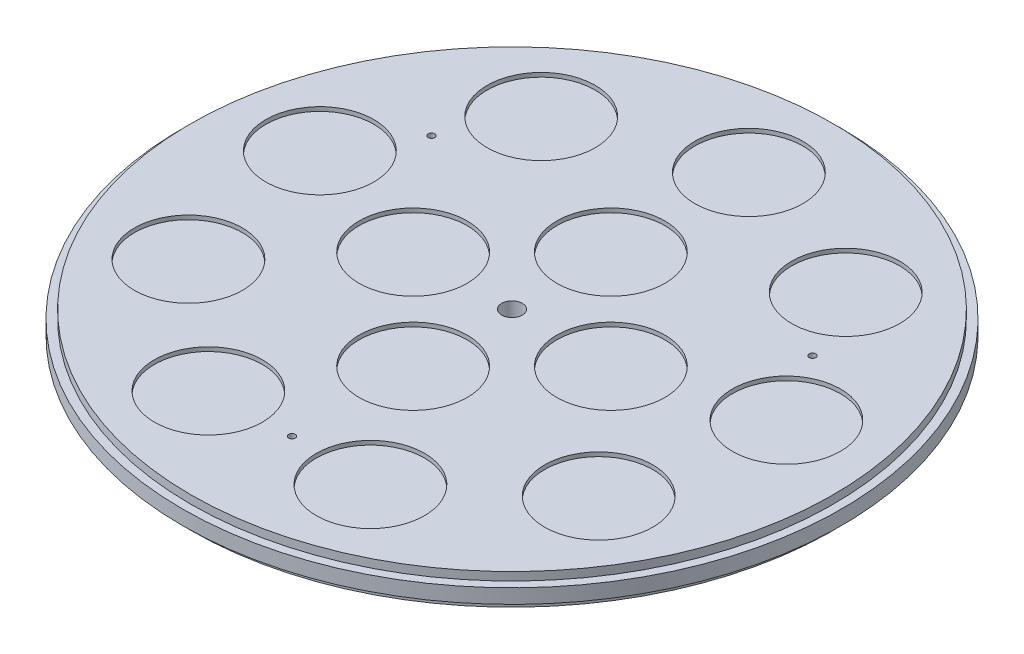
from build123d import *

# Parameters (mm, degrees)
ESQUISSE1_R                  = 160
BOSS_EXTRU_1_DEPTH           = 7.5
ESQUISSE2_R                  = 110.25
ENL_V_MAT_EXTRU_1_DEPTH      = 2
ESQUISSE3_R                  = 1.6
ENL_V_MAT_EXTRU_2_DEPTH      = 14
R_P_TITION_CIRCULAIRE1_COUNT = 3
ESQUISSE4_R                  = 1
ENL_V_MAT_EXTRU_3_DEPTH      = 14
ESQUISSE10_R                 = 5
ENL_V_MAT_EXTRU_6_DEPTH      = 11
ESQUISSE11_R                 = 160
ESQUISSE11_R_2               = 156
ENL_V_MAT_EXTRU_7_DEPTH      = 4
ESQUISSE8_R                  = 26.25
ENL_V_MAT_EXTRU_4_DEPTH      = 2
R_P_TITION_CIRCULAIRE2_COUNT = 9
ESQUISSE9_R                  = 26.25
ENL_V_MAT_EXTRU_5_DEPTH      = 2
R_P_TITION_CIRCULAIRE3_COUNT = 4


with BuildPart() as part:
    # Esquisse1 → Boss.-Extru.1 (new body, symmetric)
    with BuildSketch(Plane(origin=(0, 0, 0), x_dir=(1, 0, 0), z_dir=(0, 1, 0))):
        Circle(ESQUISSE1_R)
    extrude(amount=BOSS_EXTRU_1_DEPTH, both=True)

    # Esquisse2 → Enlèv. mat.-Extru.1 (cut)
    with BuildSketch(Plane.XZ.offset(7.5)):
        Circle(ESQUISSE2_R)
    extrude(amount=-ENL_V_MAT_EXTRU_1_DEPTH, mode=Mode.SUBTRACT)

    # Esquisse3 → Enlèv. mat.-Extru.2 (cut, through all)
    with BuildSketch(Plane(origin=(0, -5.5, 0), x_dir=(-1, 0, 0), z_dir=(0, -1, 0))):
        with Locations((0, -106.8)):
            Circle(ESQUISSE3_R)
    enl_v_mat_extru_2 = extrude(amount=-ENL_V_MAT_EXTRU_2_DEPTH, mode=Mode.SUBTRACT)

    # Répétition circulaire1: Enlèv. mat.-Extru.2 ×3 about axis
    r_p_tition_circulaire1_axis = Axis((0, 0, 0), (0, 1, 0))
    for i in range(1, R_P_TITION_CIRCULAIRE1_COUNT):
        add(enl_v_mat_extru_2.rotate(r_p_tition_circulaire1_axis, i * 360 / R_P_TITION_CIRCULAIRE1_COUNT), mode=Mode.SUBTRACT)

    # Esquisse4 → Enlèv. mat.-Extru.3 (cut, through all)
    with BuildSketch(Plane.XZ.offset(5.5)):
        Circle(ESQUISSE4_R)
    extrude(amount=-ENL_V_MAT_EXTRU_3_DEPTH, mode=Mode.SUBTRACT)

    # Esquisse10 → Enlèv. mat.-Extru.6 (cut)
    with BuildSketch(Plane(origin=(0, 7.5, 0), x_dir=(1, 0, 0), z_dir=(0, 1, 0))):
        Circle(ESQUISSE10_R)
    extrude(amount=-ENL_V_MAT_EXTRU_6_DEPTH, mode=Mode.SUBTRACT)

    # Esquisse11 → Enlèv. mat.-Extru.7 (cut)
    with BuildSketch(Plane(origin=(0, -7.5, 0), x_dir=(1, 0, 0), z_dir=(0, 1, 0))):
        Circle(ESQUISSE11_R)
        Circle(ESQUISSE11_R_2, mode=Mode.SUBTRACT)
    enl_v_mat_extru_7 = extrude(amount=ENL_V_MAT_EXTRU_7_DEPTH, mode=Mode.SUBTRACT)

    # Symétrie1: Enlèv. mat.-Extru.7 across plane
    add(enl_v_mat_extru_7.mirror(Plane.ZX), mode=Mode.SUBTRACT)

    # Esquisse8 → Enlèv. mat.-Extru.4 (cut)
    with BuildSketch(Plane(origin=(0, 7.5, 0), x_dir=(1, 0, 0), z_dir=(0, 1, 0))):
        with Locations((0, 115)):
            Circle(ESQUISSE8_R)
    enl_v_mat_extru_4 = extrude(amount=-ENL_V_MAT_EXTRU_4_DEPTH, mode=Mode.SUBTRACT)

    # Répétition circulaire2: Enlèv. mat.-Extru.4 ×9 about axis
    r_p_tition_circulaire2_axis = Axis((0, 0, 0), (0, 1, 0))
    for i in range(1, R_P_TITION_CIRCULAIRE2_COUNT):
        add(enl_v_mat_extru_4.rotate(r_p_tition_circulaire2_axis, i * 360 / R_P_TITION_CIRCULAIRE2_COUNT), mode=Mode.SUBTRACT)

    # Esquisse9 → Enlèv. mat.-Extru.5 (cut)
    with BuildSketch(Plane(origin=(0, 7.5, 0), x_dir=(1, 0, 0), z_dir=(0, 1, 0))):
        with Locations((0, 48)):
            Circle(ESQUISSE9_R)
    enl_v_mat_extru_5 = extrude(amount=-ENL_V_MAT_EXTRU_5_DEPTH, mode=Mode.SUBTRACT)

    # Répétition circulaire3: Enlèv. mat.-Extru.5 ×4 about axis
    r_p_tition_circulaire3_axis = Axis((0, 0, 0), (0, 1, 0))
    for i in range(1, R_P_TITION_CIRCULAIRE3_COUNT):
        add(enl_v_mat_extru_5.rotate(r_p_tition_circulaire3_axis, i * 360 / R_P_TITION_CIRCULAIRE3_COUNT), mode=Mode.SUBTRACT)


solid = part.part
